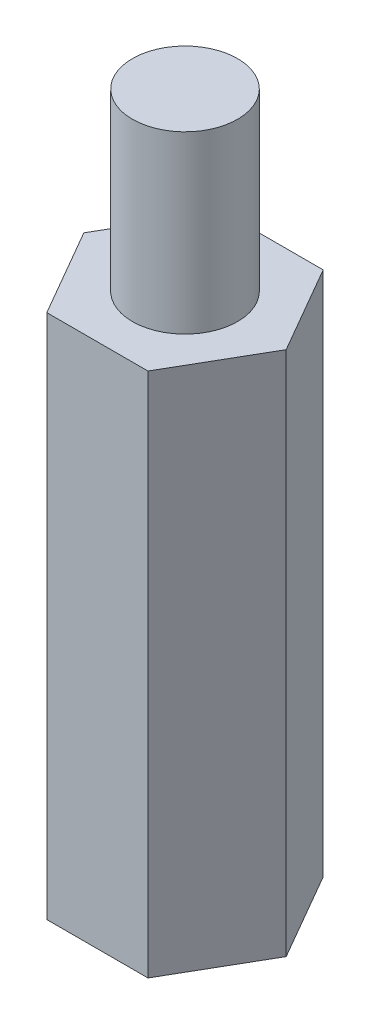
from build123d import *

# Parameters (mm, degrees)
EXTRUDE_1_DEPTH     = 15
SKETCH_2_R          = 1.5
EXTRUDE_2_DEPTH     = 5
SKETCH_3_R          = 1.5
CUT_EXTRUDE_1_DEPTH = 5


with BuildPart() as part:
    # 草圖1 → 填料-伸長1 (new body)
    with BuildSketch(Plane(origin=(0, 0, 0), x_dir=(1, 0, 0), z_dir=(0, 1, 0))):
        Polygon((2.886751346, 0), (1.443375673, 2.5), (-1.443375673, 2.5), (-2.886751346, 0), (-1.443375673, -2.5), (1.443375673, -2.5), align=None)
    extrude(amount=EXTRUDE_1_DEPTH)

    # 草圖2 → 填料-伸長2 (add)
    with BuildSketch(Plane(origin=(0, 15, 0), x_dir=(1, 0, 0), z_dir=(0, 1, 0))):
        Circle(SKETCH_2_R)
    extrude(amount=EXTRUDE_2_DEPTH)

    # 草圖3 → 除料-伸長1 (cut)
    with BuildSketch(Plane.XZ):
        Circle(SKETCH_3_R)
    extrude(amount=-CUT_EXTRUDE_1_DEPTH, mode=Mode.SUBTRACT)


solid = part.part
